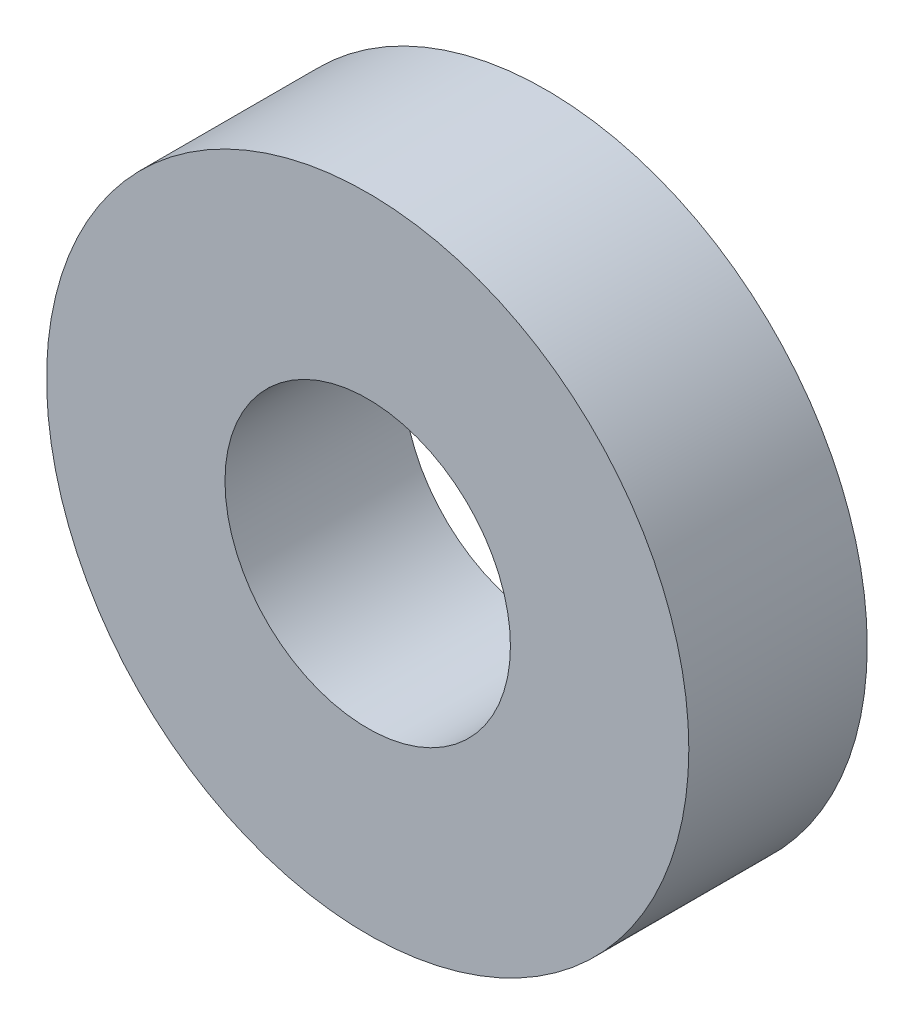
from build123d import *

# Parameters (mm, degrees)
SKETCH_1_R      = 4.5
SKETCH_1_R_2    = 2
EXTRUDE_1_DEPTH = 2.5


with BuildPart() as part:
    # 草图1 → 凸台-拉伸1 (new body)
    with BuildSketch(Plane.XY):
        Circle(SKETCH_1_R)
        Circle(SKETCH_1_R_2, mode=Mode.SUBTRACT)
    extrude(amount=EXTRUDE_1_DEPTH)


solid = part.part
